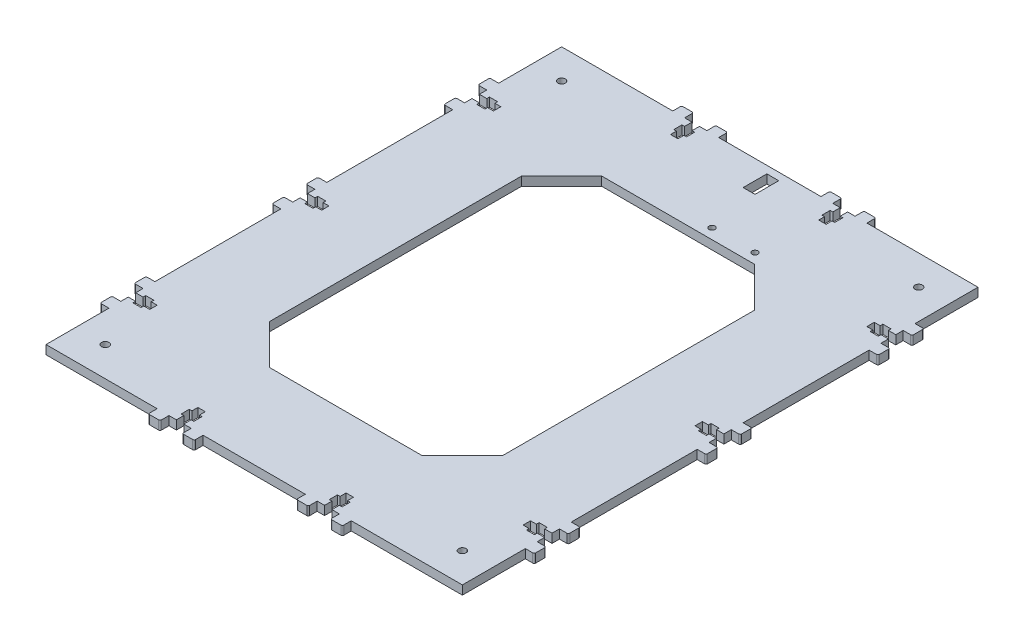
from build123d import *

# Parameters (mm, degrees)
ESQUISSE2_R              = 2.5
PLAQUE_DEPTH             = 3
BOSS_EXTRU_8_DEPTH       = 6
ENL_V_MAT_EXTRU_8_DEPTH  = 6
CHANFREIN1_SIZE          = 27
BOSS_EXTRU_10_DEPTH      = 6
ENL_V_MAT_EXTRU_10_DEPTH = 6
ENL_V_MAT_EXTRU_11_REACH = 234.16
ESQUISSE14_R             = 2
ESQUISSE14_W             = 8
ESQUISSE14_H             = 16


with BuildPart() as part:
    # Esquisse2 → plaque (new, symmetric)
    with BuildSketch(Plane(origin=(0, 0, 0), x_dir=(1, 0, 0), z_dir=(0, 1, 0))):
        Polygon((-140.5, 174), (0, 174), (0, 112), (-78.5, 112), (-78.5, 0), (-140.5, 0), align=None)
        with Locations((-120.5, 154)):
            Circle(ESQUISSE2_R, mode=Mode.SUBTRACT)
    extrude(amount=PLAQUE_DEPTH, both=True)

    # Esquisse10 → Boss.-Extru.8 (add)
    with BuildSketch(Plane(origin=(0, 3, 0), x_dir=(1, 0, 0), z_dir=(0, 1, 0))):
        with BuildLine():
            Line((-42.5, 179), (-42.5, 174))
            Line((-42.5, 174), (-34.5, 174))
            Line((-34.5, 174), (-34.5, 179))
            ThreePointArc((-34.5, 179), (-34.792893219, 179.707106781), (-35.5, 180))
            Line((-35.5, 180), (-41.5, 180))
            ThreePointArc((-41.5, 180), (-42.207106781, 179.707106781), (-42.5, 179))
        make_face()
        with BuildLine():
            Line((-65.5, 179), (-65.5, 174))
            Line((-65.5, 174), (-57.5, 174))
            Line((-57.5, 174), (-57.5, 179))
            ThreePointArc((-57.5, 179), (-57.792893219, 179.707106781), (-58.5, 180))
            Line((-58.5, 180), (-64.5, 180))
            ThreePointArc((-64.5, 180), (-65.207106781, 179.707106781), (-65.5, 179))
        make_face()
        with BuildLine():
            Line((-145.5, 123.5), (-140.5, 123.5))
            Line((-140.5, 123.5), (-140.5, 131.5))
            Line((-140.5, 131.5), (-145.5, 131.5))
            ThreePointArc((-145.5, 131.5), (-146.207106781, 131.207106781), (-146.5, 130.5))
            Line((-146.5, 130.5), (-146.5, 124.5))
            ThreePointArc((-146.5, 124.5), (-146.207106781, 123.792893219), (-145.5, 123.5))
        make_face()
        with BuildLine():
            Line((-145.5, 100.5), (-140.5, 100.5))
            Line((-140.5, 100.5), (-140.5, 108.5))
            Line((-140.5, 108.5), (-145.5, 108.5))
            ThreePointArc((-145.5, 108.5), (-146.207106781, 108.207106781), (-146.5, 107.5))
            Line((-146.5, 107.5), (-146.5, 101.5))
            ThreePointArc((-146.5, 101.5), (-146.207106781, 100.792893219), (-145.5, 100.5))
        make_face()
    extrude(amount=-BOSS_EXTRU_8_DEPTH)

    # Esquisse10_3 → Enl_v. mat.-Extru.8 (cut)
    with BuildSketch(Plane(origin=(0, 3, 0), x_dir=(1, 0, 0), z_dir=(0, 1, 0))):
        Polygon((-47.5, 174), (-52.5, 174), (-52.5, 169), (-54.3, 169), (-54.3, 163.5), (-52.5, 163.5), (-52.5, 159.5), (-47.5, 159.5), (-47.5, 163.5), (-45.7, 163.5), (-45.7, 169), (-47.5, 169), align=None)
        Polygon((-140.5, 118.5), (-140.5, 113.5), (-135.5, 113.5), (-135.5, 111.7), (-130, 111.7), (-130, 113.5), (-126, 113.5), (-126, 118.5), (-130, 118.5), (-130, 120.3), (-135.5, 120.3), (-135.5, 118.5), align=None)
    extrude(amount=-ENL_V_MAT_EXTRU_8_DEPTH, mode=Mode.SUBTRACT)

    # Chanfrein1
    chanfrein1_edges = [part.edges().sort_by_distance(p)[0] for p in [
        (-78.5, 0, -112),
    ]]
    chamfer(chanfrein1_edges, length=CHANFREIN1_SIZE)

    # Sym_trie6: part across plane


with BuildPart() as part_1:
    add(part.part)
    add(part.part.mirror(Plane(origin=(-140.5, 3, 0), x_dir=(1, 0, 0), z_dir=(0, 0, -1))))

    # Esquisse13 → Boss.-Extru.10 (add)
    with BuildSketch(Plane(origin=(0, 3, 0), x_dir=(1, 0, 0), z_dir=(0, 1, 0))):
        with BuildLine():
            Line((-145.5, 7.5), (-140.5, 7.5))
            Line((-140.5, 7.5), (-140.5, 15.5))
            Line((-140.5, 15.5), (-145.5, 15.5))
            ThreePointArc((-145.5, 15.5), (-146.207106781, 15.207106781), (-146.5, 14.5))
            Line((-146.5, 14.5), (-146.5, 8.5))
            ThreePointArc((-146.5, 8.5), (-146.207106781, 7.792893219), (-145.5, 7.5))
        make_face()
        with BuildLine():
            Line((-145.5, -15.5), (-140.5, -15.5))
            Line((-140.5, -15.5), (-140.5, -7.5))
            Line((-140.5, -7.5), (-145.5, -7.5))
            ThreePointArc((-145.5, -7.5), (-146.207106781, -7.792893219), (-146.5, -8.5))
            Line((-146.5, -8.5), (-146.5, -14.5))
            ThreePointArc((-146.5, -14.5), (-146.207106781, -15.207106781), (-145.5, -15.5))
        make_face()
    extrude(amount=-BOSS_EXTRU_10_DEPTH)

    # Esquisse13_3 → Enl_v. mat.-Extru.10 (cut)
    with BuildSketch(Plane(origin=(0, 3, 0), x_dir=(1, 0, 0), z_dir=(0, 1, 0))):
        Polygon((-140.5, 2.5), (-140.5, -2.5), (-135.5, -2.5), (-135.5, -4.3), (-130, -4.3), (-130, -2.5), (-126, -2.5), (-126, 2.5), (-130, 2.5), (-130, 4.3), (-135.5, 4.3), (-135.5, 2.5), align=None)
    extrude(amount=-ENL_V_MAT_EXTRU_10_DEPTH, mode=Mode.SUBTRACT)

    # Sym_trie5: part across plane


with BuildPart() as part_2:
    add(part_1.part)
    add(part_1.part.mirror(Plane(origin=(0, 3, -174), x_dir=(0, 0, 1), z_dir=(-1, 0, 0))))

    # Esquisse14 → Enl_v. mat.-Extru.11 (cut, up to next)
    with BuildSketch(Plane(origin=(0, -3, 0), x_dir=(-1, 0, 0), z_dir=(0, -1, 0)), mode=Mode.PRIVATE) as enl_v_mat_extru_11_sk1:
        with Locations((-16, 119)):
            Circle(ESQUISSE14_R)
    enl_v_mat_extru_11_tool1 = extrude(enl_v_mat_extru_11_sk1.sketch, amount=-ENL_V_MAT_EXTRU_11_REACH, mode=Mode.PRIVATE) & part_2.part
    # Esquisse14 → Enl_v. mat.-Extru.11 (cut, up to next)
    with BuildSketch(Plane(origin=(0, -3, 0), x_dir=(-1, 0, 0), z_dir=(0, -1, 0)), mode=Mode.PRIVATE) as enl_v_mat_extru_11_sk2:
        with Locations((-45, 119)):
            Circle(ESQUISSE14_R)
    enl_v_mat_extru_11_tool2 = extrude(enl_v_mat_extru_11_sk2.sketch, amount=-ENL_V_MAT_EXTRU_11_REACH, mode=Mode.PRIVATE) & part_2.part
    # Esquisse14 → Enl_v. mat.-Extru.11 (cut, up to next)
    with BuildSketch(Plane(origin=(0, -3, 0), x_dir=(-1, 0, 0), z_dir=(0, -1, 0)), mode=Mode.PRIVATE) as enl_v_mat_extru_11_sk3:
        with Locations((-7, 161)):
            Rectangle(ESQUISSE14_W, ESQUISSE14_H)
    enl_v_mat_extru_11_tool3 = extrude(enl_v_mat_extru_11_sk3.sketch, amount=-ENL_V_MAT_EXTRU_11_REACH, mode=Mode.PRIVATE) & part_2.part
    add(enl_v_mat_extru_11_tool1.solids().sort_by_distance((16, -3, -119))[0], mode=Mode.SUBTRACT)
    add(enl_v_mat_extru_11_tool2.solids().sort_by_distance((45, -3, -119))[0], mode=Mode.SUBTRACT)
    add(enl_v_mat_extru_11_tool3.solids().sort_by_distance((7, -3, -161))[0], mode=Mode.SUBTRACT)


solid = part_2.part
